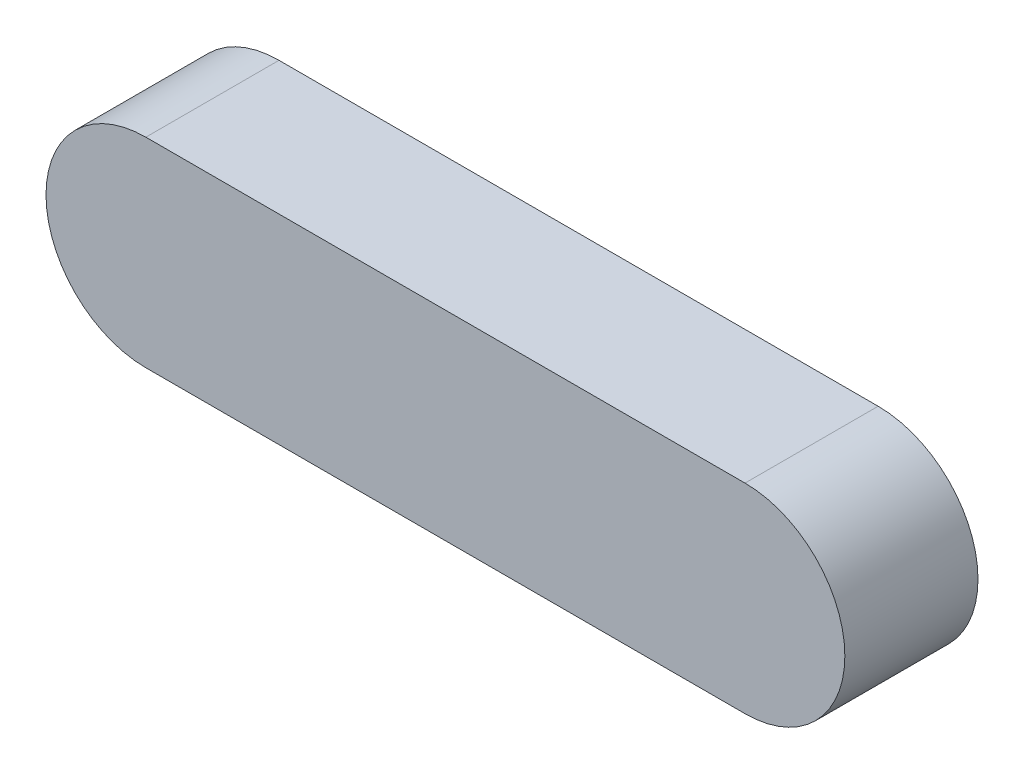
from build123d import *

# Parameters (mm, degrees)
BOSS_EXTRUDE1_DEPTH = 8


with BuildPart() as part:
    # Sketch2 → Boss-Extrude1 (new body)
    with BuildSketch(Plane.XY):
        with BuildLine():
            Line((-3.619047619, 6), (32.380952381, 6))
            ThreePointArc((32.380952381, 6), (38.380952381, 0), (32.380952381, -6))
            Line((32.380952381, -6), (-3.619047619, -6))
            ThreePointArc((-3.619047619, -6), (-9.619047619, 0), (-3.619047619, 6))
        make_face()
    extrude(amount=BOSS_EXTRUDE1_DEPTH)


solid = part.part
